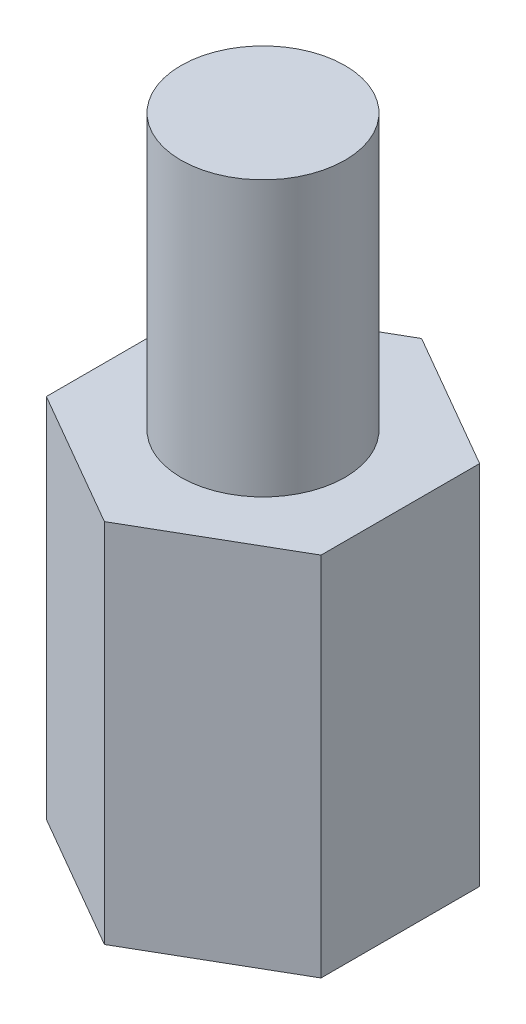
from build123d import *

# Parameters (mm, degrees)
BOSS_EXTRUDE1_DEPTH = 6.35
SKETCH2_R           = 1.4224
BOSS_EXTRUDE2_DEPTH = 4.7625
SKETCH7_R           = 1.4224
CUT_EXTRUDE4_DEPTH  = 4.7625


with BuildPart() as part:
    # Sketch1 → Boss-Extrude1 (new body)
    with BuildSketch(Plane(origin=(0, 0, 0), x_dir=(1, 0, 0), z_dir=(0, 1, 0))):
        Polygon((-2.38125, 1.374815329), (-2.38125, -1.374815329), (0, -2.749630657), (2.38125, -1.374815329), (2.38125, 1.374815329), (0, 2.749630657), align=None)
    extrude(amount=BOSS_EXTRUDE1_DEPTH)

    # Sketch2 → Boss-Extrude2 (add)
    with BuildSketch(Plane(origin=(0, 6.35, 0), x_dir=(1, 0, 0), z_dir=(0, 1, 0))):
        Circle(SKETCH2_R)
    extrude(amount=BOSS_EXTRUDE2_DEPTH)

    # Sketch7 → Cut-Extrude4 (cut)
    with BuildSketch(Plane.XZ):
        Circle(SKETCH7_R)
    extrude(amount=-CUT_EXTRUDE4_DEPTH, mode=Mode.SUBTRACT)


solid = part.part
